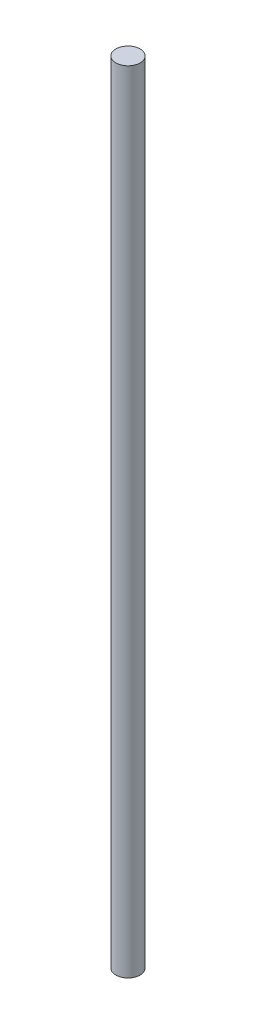
from build123d import *

# Parameters (mm, degrees)
SKETCH1_R           = 914.4
BOSS_EXTRUDE1_DEPTH = 59500.978401412


with BuildPart() as part:
    # Sketch1 → Boss-Extrude1 (new body)
    with BuildSketch(Plane(origin=(0, 0, 0), x_dir=(1, 0, 0), z_dir=(0, 1, 0))):
        Circle(SKETCH1_R)
    extrude(amount=BOSS_EXTRUDE1_DEPTH)


solid = part.part
